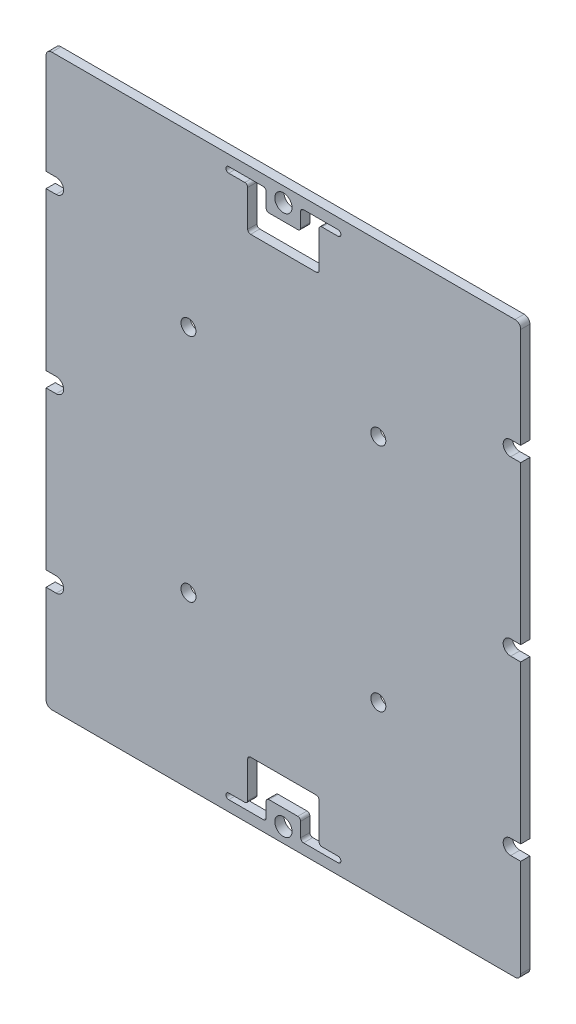
from build123d import *

# Parameters (mm, degrees)
SKETCH2_W            = 82.5
SKETCH2_H            = 99
SKETCH2_R            = 0.8
SKETCH2_R_2          = 1.5
PCB_EXTRUDE_DEPTH    = 0.8
CORNER_FILLETS_R     = 1
SKETCH4_R            = 1.5
SOLAR_HOLES_DEPTH    = 65.454421881
SOLAR_HOLE_FILLETS_R = 0.5
M2_CLEARANCE_HOLES_D = 2.6
SKETCH10_W           = 1.75
SKETCH10_H           = 2.6
CUT_EXTRUDE2_DEPTH   = 65.454421881


with BuildPart() as part:
    # Sketch2 → pcb extrude (new, symmetric)
    with BuildSketch(Plane.XY):
        Rectangle(SKETCH2_W, SKETCH2_H)
        with Locations((-39.5, -30.25)):
            Circle(SKETCH2_R, mode=Mode.SUBTRACT)
        with Locations((-39.5, -0.25)):
            Circle(SKETCH2_R, mode=Mode.SUBTRACT)
        with Locations((-16.5, -20)):
            Circle(SKETCH2_R, mode=Mode.SUBTRACT)
        with Locations((0, -46.95)):
            Circle(SKETCH2_R_2, mode=Mode.SUBTRACT)
        with Locations((39.5, -30.25)):
            Circle(SKETCH2_R, mode=Mode.SUBTRACT)
        with Locations((16.5, -20)):
            Circle(SKETCH2_R, mode=Mode.SUBTRACT)
        with Locations((39.5, -0.25)):
            Circle(SKETCH2_R, mode=Mode.SUBTRACT)
        with Locations((-16.5, 20)):
            Circle(SKETCH2_R, mode=Mode.SUBTRACT)
        with Locations((-39.5, 29.75)):
            Circle(SKETCH2_R, mode=Mode.SUBTRACT)
        with Locations((16.5, 20)):
            Circle(SKETCH2_R, mode=Mode.SUBTRACT)
        with Locations((0, 46.95)):
            Circle(SKETCH2_R, mode=Mode.SUBTRACT)
        with Locations((39.5, 29.75)):
            Circle(SKETCH2_R, mode=Mode.SUBTRACT)
    extrude(amount=PCB_EXTRUDE_DEPTH, both=True)

    # corner fillets
    corner_fillets_edges = [part.edges().sort_by_distance(p)[0] for p in [
        (41.25, -49.5, 0),
        (-41.25, -49.5, 0),
        (41.25, 49.5, 0),
        (-41.25, 49.5, 0),
    ]]
    fillet(corner_fillets_edges, radius=CORNER_FILLETS_R)

    # Sketch4 → solar holes (cut, through all)
    with BuildSketch(Plane.XY.offset(0.8)):
        with Locations((0, 46.95)):
            Circle(SKETCH4_R)
        with BuildLine():
            Line((6.2, 39.35), (-6.2, 39.35))
            Line((-6.2, 39.35), (-6.2, 46.65))
            Line((-6.2, 46.65), (-9.5, 46.65))
            ThreePointArc((-9.5, 46.65), (-10, 47.15), (-9.5, 47.65))
            Line((-9.5, 47.65), (-3, 47.65))
            Line((-3, 47.65), (-3, 44.15))
            Line((-3, 44.15), (3, 44.15))
            Line((3, 44.15), (3, 47.65))
            Line((3, 47.65), (9.5, 47.65))
            ThreePointArc((9.5, 47.65), (10, 47.15), (9.5, 46.65))
            Line((9.5, 46.65), (6.2, 46.65))
            Line((6.2, 46.65), (6.2, 39.35))
        make_face()
        with BuildLine():
            Line((6.2, -46.65), (9.5, -46.65))
            ThreePointArc((9.5, -46.65), (10, -47.15), (9.5, -47.65))
            Line((9.5, -47.65), (3, -47.65))
            Line((3, -47.65), (3, -44.15))
            Line((3, -44.15), (-3, -44.15))
            Line((-3, -44.15), (-3, -47.65))
            Line((-3, -47.65), (-9.5, -47.65))
            ThreePointArc((-9.5, -47.65), (-10, -47.15), (-9.5, -46.65))
            Line((-9.5, -46.65), (-6.2, -46.65))
            Line((-6.2, -46.65), (-6.2, -39.35))
            Line((-6.2, -39.35), (6.2, -39.35))
            Line((6.2, -39.35), (6.2, -46.65))
        make_face()
    extrude(amount=-SOLAR_HOLES_DEPTH, mode=Mode.SUBTRACT)

    # solar hole fillets
    solar_hole_fillets_edges = [part.edges().sort_by_distance(p)[0] for p in [
        (6.2, 46.65, 0),
        (3, 47.65, 0),
        (3, 44.15, 0),
        (6.2, 39.35, 0),
        (-6.2, 39.35, 0),
        (-6.2, 46.65, 0),
        (-3, 44.15, 0),
        (-3, 47.65, 0),
        (3, -47.65, 0),
        (3, -44.15, 0),
        (-3, -47.65, 0),
        (-3, -44.15, 0),
        (-6.2, -46.65, 0),
        (6.2, -46.65, 0),
        (6.2, -39.35, 0),
        (-6.2, -39.35, 0),
    ]]
    fillet(solar_hole_fillets_edges, radius=SOLAR_HOLE_FILLETS_R)

    # M2 Clearance Holes (through all)
    with Locations(Plane.XY.offset(0.8)):
        with Locations((-39.5, 29.75), (-39.5, -0.25), (-16.5, 20), (16.5, 20), (16.5, -20), (-16.5, -20), (39.5, 29.75), (39.5, -0.25), (39.5, -30.25), (-39.5, -30.25)):
            Hole(M2_CLEARANCE_HOLES_D / 2)

    # Sketch10 → Cut-Extrude2 (cut, through all)
    with BuildSketch(Plane.XY.offset(0.8)):
        with Locations((-40.375, 29.75)):
            Rectangle(SKETCH10_W, SKETCH10_H)
        with Locations((-40.375, -0.25)):
            Rectangle(SKETCH10_W, SKETCH10_H)
        with Locations((-40.375, -30.25)):
            Rectangle(SKETCH10_W, SKETCH10_H)
        with Locations((40.375, -30.25)):
            Rectangle(SKETCH10_W, SKETCH10_H)
        with Locations((40.375, -0.25)):
            Rectangle(SKETCH10_W, SKETCH10_H)
        with Locations((40.375, 29.75)):
            Rectangle(SKETCH10_W, SKETCH10_H)
    extrude(amount=-CUT_EXTRUDE2_DEPTH, mode=Mode.SUBTRACT)


solid = part.part
